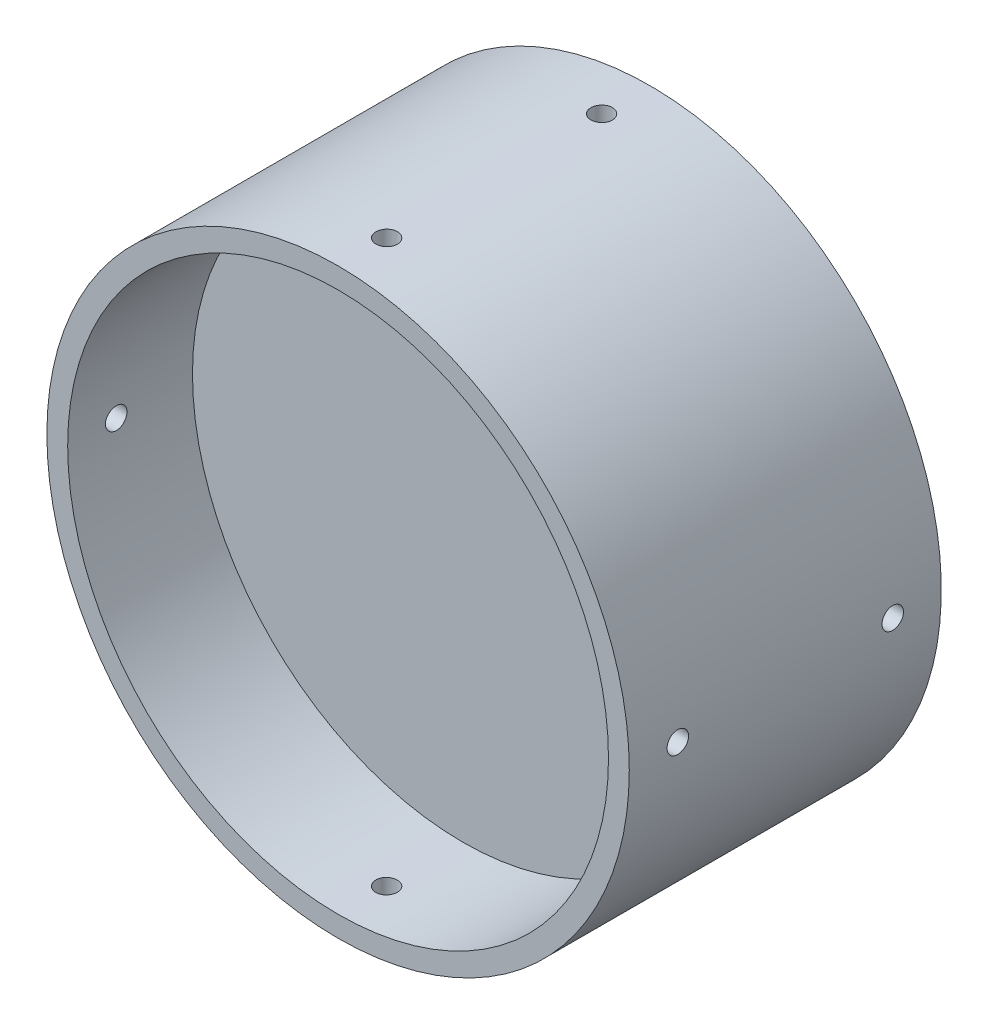
from build123d import *

# Parameters (mm, degrees)
ESQUISSE1_R                  = 42
BOSS_EXTRU_1_DEPTH           = 33
R_P_TITION_CIRCULAIRE1_COUNT = 4
ESQUISSE5_R                  = 35
ENL_V_MAT_EXTRU_1_DEPTH      = 13
ESQUISSE7_R                  = 39
ENL_V_MAT_EXTRU_2_DEPTH      = 18
R_P_TITION_CIRCULAIRE2_COUNT = 4
ESQUISSE14_W                 = 3
ESQUISSE14_H                 = 12
R_P_TITION_CIRCULAIRE3_COUNT = 4


with BuildPart() as part:
    # Esquisse1 → Boss.-Extru.1 (new body)
    with BuildSketch(Plane.XY):
        Circle(ESQUISSE1_R)
    extrude(amount=BOSS_EXTRU_1_DEPTH)

    # Esquisse3 → Trou taraudé M21 (revolve, cut)
    with BuildSketch(Plane(origin=(-26.162950904, 26.162950904, 0), x_dir=(0, 1, 0), z_dir=(1, 0, 0))):
        Polygon((0, 0), (0, 6.480688495), (0.8, 6), (0.8, 0), align=None)
    trou_taraud_m21 = revolve(axis=Axis((-26.162950904, 26.162950904, -6.35), (0, 0, 1)), mode=Mode.SUBTRACT)

    # Répétition circulaire1: Trou taraudé M21 ×4 about axis
    r_p_tition_circulaire1_axis = Axis((0, 0, 0), (0, 0, 1))
    for i in range(1, R_P_TITION_CIRCULAIRE1_COUNT):
        add(trou_taraud_m21.rotate(r_p_tition_circulaire1_axis, i * 360 / R_P_TITION_CIRCULAIRE1_COUNT), mode=Mode.SUBTRACT)

    # Esquisse5 → Enlèv. mat.-Extru.1 (cut)
    with BuildSketch(Plane(origin=(0, 0, 0), x_dir=(-1, 0, 0), z_dir=(0, 0, -1))):
        Circle(ESQUISSE5_R)
    extrude(amount=-ENL_V_MAT_EXTRU_1_DEPTH, mode=Mode.SUBTRACT)

    # Esquisse7 → Enlèv. mat.-Extru.2 (cut)
    with BuildSketch(Plane.XY.offset(33)):
        Circle(ESQUISSE7_R)
    extrude(amount=-ENL_V_MAT_EXTRU_2_DEPTH, mode=Mode.SUBTRACT)

    # Esquisse13 → Dégagement M2.51 (revolve, cut)
    with BuildSketch(Plane(origin=(42, 0, 26), x_dir=(0, 0, -1), z_dir=(0, 1, 0))):
        Polygon((0, 0), (0, 10.931333959), (1.55, 10), (1.55, 0), align=None)
    d_gagement_m2_51 = revolve(axis=Axis((48.35, 0, 26), (-1, 0, 0)), mode=Mode.SUBTRACT)

    # Répétition circulaire2: Dégagement M2.51 ×4 about axis
    r_p_tition_circulaire2_axis = Axis((0, 0, 33), (0, 0, 1))
    for i in range(1, R_P_TITION_CIRCULAIRE2_COUNT):
        add(d_gagement_m2_51.rotate(r_p_tition_circulaire2_axis, i * 360 / R_P_TITION_CIRCULAIRE2_COUNT), mode=Mode.SUBTRACT)

    # Esquisse14 → Révolution1 (revolve)
    with BuildSketch(Plane(origin=(0, 0, 0), x_dir=(1, 0, 0), z_dir=(0, 1, 0))):
        with Locations((40.5, 6)):
            Rectangle(ESQUISSE14_W, ESQUISSE14_H)
    revolve(axis=Axis((0, 0, -20.123212499), (0, 0, 1)))

    # Esquisse15 → Dégagement M2.52 (revolve, cut)
    with BuildSketch(Plane(origin=(42, 0, -5), x_dir=(0, 0, -1), z_dir=(0, 1, 0))):
        Polygon((0, 0), (0, 9.431333959), (1.55, 8.5), (1.55, 0), align=None)
    d_gagement_m2_52 = revolve(axis=Axis((48.35, 0, -5), (-1, 0, 0)), mode=Mode.SUBTRACT)

    # Répétition circulaire3: Dégagement M2.52 ×4 about axis
    r_p_tition_circulaire3_axis = Axis((0, 0, 0), (0, 0, -1))
    for i in range(1, R_P_TITION_CIRCULAIRE3_COUNT):
        add(d_gagement_m2_52.rotate(r_p_tition_circulaire3_axis, i * 360 / R_P_TITION_CIRCULAIRE3_COUNT), mode=Mode.SUBTRACT)


solid = part.part
